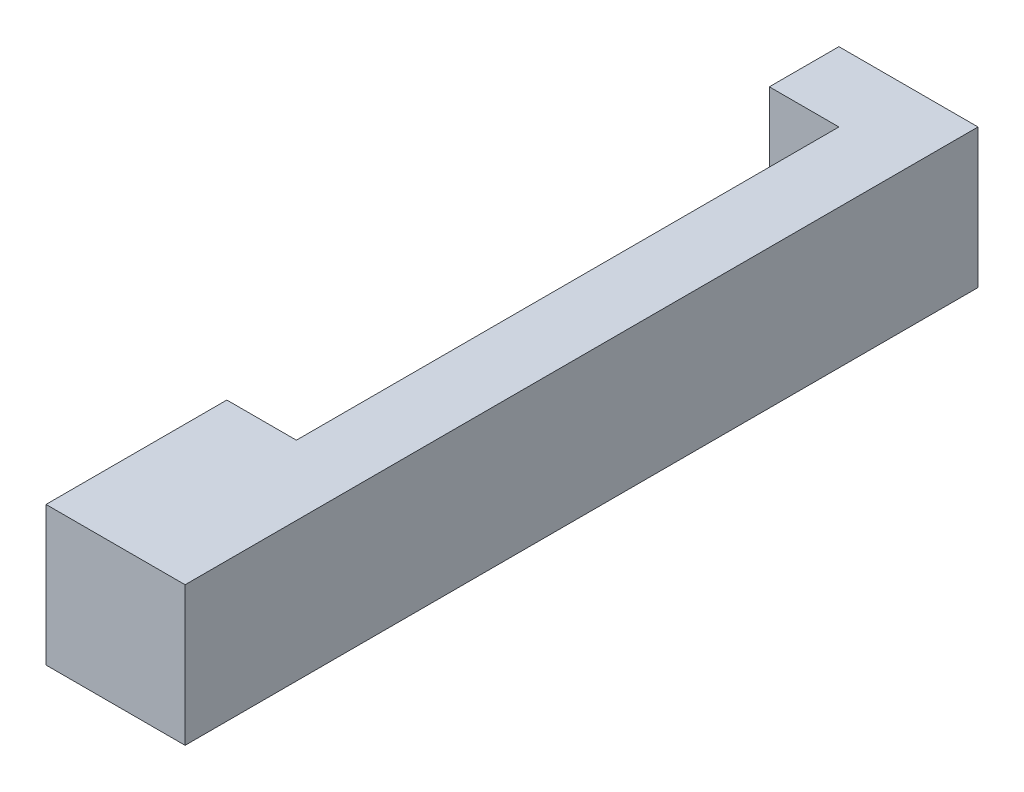
from build123d import *

# Parameters (mm, degrees)
SKETCH1_W           = 25.4
SKETCH1_H           = 33.02
SKETCH1_W_2         = 12.7
SKETCH1_H_2         = 12.7
BOSS_EXTRUDE1_DEPTH = 25.4


with BuildPart() as part:
    # Sketch1 → Boss-Extrude1 (new body)
    with BuildSketch(Plane(origin=(0, 0, 0), x_dir=(1, 0, 0), z_dir=(0, 1, 0))):
        with Locations((-12.7, 16.51)):
            Rectangle(SKETCH1_W, SKETCH1_H)
        Polygon((-12.7, 33.02), (0, 33.02), (0, 144.78), (-12.7, 144.78), (-12.7, 132.08), align=None)
        with Locations((-19.05, 138.43)):
            Rectangle(SKETCH1_W_2, SKETCH1_H_2)
    extrude(amount=BOSS_EXTRUDE1_DEPTH)


solid = part.part
